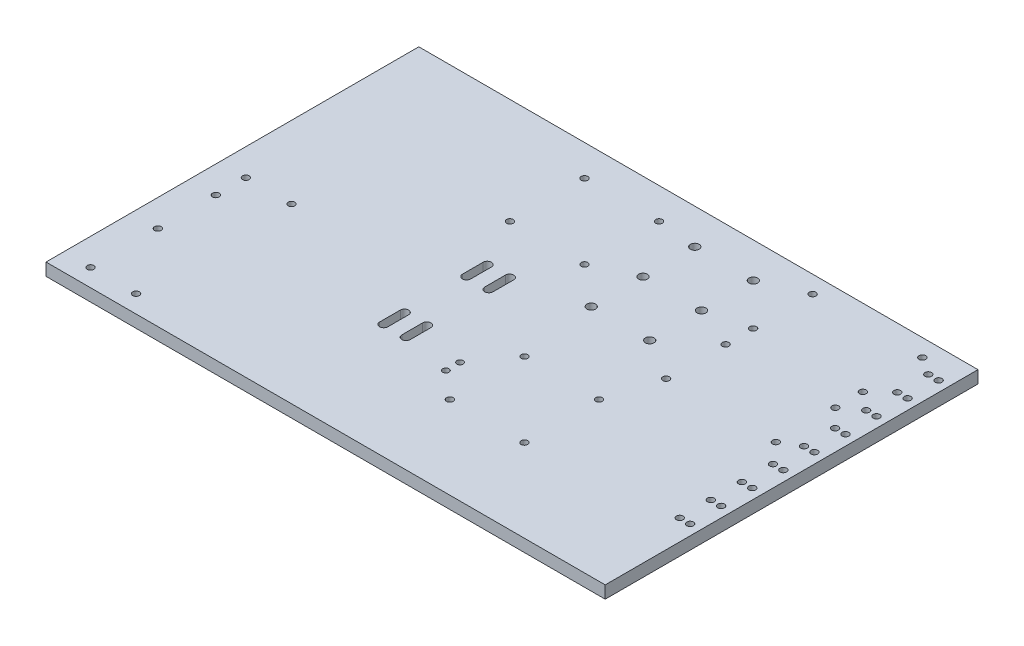
from build123d import *

# Parameters (mm, degrees)
SKETCH1_W           = 270
SKETCH1_H           = 180
BOSS_EXTRUDE1_DEPTH = 6
SKETCH2_R           = 1.6
CUT_EXTRUDE1_DEPTH  = 7
SKETCH3_R           = 1.6
CUT_EXTRUDE2_DEPTH  = 10
SKETCH4_R           = 1.6
SKETCH4_R_2         = 1.5
CUT_EXTRUDE3_DEPTH  = 7
SKETCH5_R           = 1.6
CUT_EXTRUDE4_DEPTH  = 10
SKETCH6_R           = 2.1
CUT_EXTRUDE5_DEPTH  = 10


with BuildPart() as part:
    # Sketch1 → Boss-Extrude1 (new body)
    with BuildSketch(Plane(origin=(0, 0, 0), x_dir=(1, 0, 0), z_dir=(0, 1, 0))):
        Rectangle(SKETCH1_W, SKETCH1_H)
    extrude(amount=BOSS_EXTRUDE1_DEPTH)

    # Sketch2 → Cut-Extrude1 (cut, through all)
    with BuildSketch(Plane.XZ):
        with Locations((-122, 81.5)):
            Circle(SKETCH2_R)
        with Locations((-100.000000181, 81.5)):
            Circle(SKETCH2_R)
        with Locations((-122, 6.500000003)):
            Circle(SKETCH2_R)
        with Locations((-100.000000181, 6.500000003)):
            Circle(SKETCH2_R)
        with Locations((-122, 21.000003407)):
            Circle(SKETCH2_R)
        with Locations((-122, 49.000003407)):
            Circle(SKETCH2_R)
    extrude(amount=-CUT_EXTRUDE1_DEPTH, mode=Mode.SUBTRACT)

    # Sketch3 → Cut-Extrude2 (cut)
    with BuildSketch(Plane.XZ):
        with Locations((-40, -39)):
            Circle(SKETCH3_R)
        with Locations((-40, -75)):
            Circle(SKETCH3_R)
        with Locations((-4, -75)):
            Circle(SKETCH3_R)
        with Locations((-4, -39)):
            Circle(SKETCH3_R)
        with BuildLine():
            Line((-29.38, -15.458502607), (-29.38, -5.458502607))
            ThreePointArc((-29.38, -5.458502607), (-27.38, -3.458502607), (-25.38, -5.458502607))
            Line((-25.38, -5.458502607), (-25.38, -15.458502607))
            ThreePointArc((-25.38, -15.458502607), (-27.38, -17.458502607), (-29.38, -15.458502607))
        make_face()
        with BuildLine():
            Line((-14.63, -15.458502607), (-14.63, -5.458502607))
            ThreePointArc((-14.63, -5.458502607), (-16.63, -3.458502607), (-18.63, -5.458502607))
            Line((-18.63, -5.458502607), (-18.63, -15.458502607))
            ThreePointArc((-18.63, -15.458502607), (-16.63, -17.458502607), (-14.63, -15.458502607))
        make_face()
        with BuildLine():
            Line((-29.38, 24.541497393), (-29.38, 34.541497393))
            ThreePointArc((-29.38, 34.541497393), (-27.38, 36.541497393), (-25.38, 34.541497393))
            Line((-25.38, 34.541497393), (-25.38, 24.541497393))
            ThreePointArc((-25.38, 24.541497393), (-27.38, 22.541497393), (-29.38, 24.541497393))
        make_face()
        with BuildLine():
            Line((-14.63, 24.541497393), (-14.63, 34.541497393))
            ThreePointArc((-14.63, 34.541497393), (-16.63, 36.541497393), (-18.63, 34.541497393))
            Line((-18.63, 34.541497393), (-18.63, 24.541497393))
            ThreePointArc((-18.63, 24.541497393), (-16.63, 22.541497393), (-14.63, 24.541497393))
        make_face()
    extrude(amount=-CUT_EXTRUDE2_DEPTH, mode=Mode.SUBTRACT)

    # Sketch4 → Cut-Extrude3 (cut, through all)
    with BuildSketch(Plane(origin=(0, 6, 0), x_dir=(1, 0, 0), z_dir=(0, 1, 0))):
        with Locations((19.999964, -14)):
            Circle(SKETCH4_R)
        with Locations((55.999928, -14.000072)):
            Circle(SKETCH4_R)
        with Locations((20, -50)):
            Circle(SKETCH4_R)
        with Locations((55.999928, -50)):
            Circle(SKETCH4_R)
        with Locations((6.904969305, -32.000108)):
            Circle(SKETCH4_R_2)
        with Locations((6.904969305, -38.817254)):
            Circle(SKETCH4_R_2)
    extrude(amount=-CUT_EXTRUDE3_DEPTH, mode=Mode.SUBTRACT)

    # Sketch5 → Cut-Extrude4 (cut)
    with BuildSketch(Plane(origin=(0, 6, 0), x_dir=(1, 0, 0), z_dir=(0, 1, 0))):
        with Locations((116.5, 10.91154574)):
            Circle(SKETCH5_R)
        with Locations((63.5, 10.91154574)):
            Circle(SKETCH5_R)
        with Locations((116.5, 39.629776512)):
            Circle(SKETCH5_R)
        with Locations((63.5, 39.629776512)):
            Circle(SKETCH5_R)
        with Locations((116.5, 52.91154574)):
            Circle(SKETCH5_R)
        with Locations((63.5, 52.91154574)):
            Circle(SKETCH5_R)
        with Locations((116.5, 81.629776512)):
            Circle(SKETCH5_R)
        with Locations((63.5, 81.629776512)):
            Circle(SKETCH5_R)
        with Locations((125, 76.00062614)):
            Circle(SKETCH5_R)
        with Locations((130, 76.00062614)):
            Circle(SKETCH5_R)
        with Locations((125, 61.00062614)):
            Circle(SKETCH5_R)
        with Locations((130, 61.00062614)):
            Circle(SKETCH5_R)
        with Locations((125, 46.00062614)):
            Circle(SKETCH5_R)
        with Locations((130, 46.00062614)):
            Circle(SKETCH5_R)
        with Locations((125, 31.00062614)):
            Circle(SKETCH5_R)
        with Locations((130, 31.00062614)):
            Circle(SKETCH5_R)
        with Locations((125, 16.00062614)):
            Circle(SKETCH5_R)
        with Locations((130, 16.00062614)):
            Circle(SKETCH5_R)
        with Locations((125, 1.00062614)):
            Circle(SKETCH5_R)
        with Locations((130, 1.00062614)):
            Circle(SKETCH5_R)
        with Locations((125, -13.99937386)):
            Circle(SKETCH5_R)
        with Locations((130, -13.99937386)):
            Circle(SKETCH5_R)
        with Locations((125, -28.99937386)):
            Circle(SKETCH5_R)
        with Locations((130, -28.99937386)):
            Circle(SKETCH5_R)
        with Locations((125, -43.99937386)):
            Circle(SKETCH5_R)
        with Locations((130, -43.99937386)):
            Circle(SKETCH5_R)
    extrude(amount=-CUT_EXTRUDE4_DEPTH, mode=Mode.SUBTRACT)

    # Sketch6 → Cut-Extrude5 (cut)
    with BuildSketch(Plane(origin=(0, 6, 0), x_dir=(1, 0, 0), z_dir=(0, 1, 0))):
        with Locations((15.26, 73)):
            Circle(SKETCH6_R)
        with Locations((43.5, 73)):
            Circle(SKETCH6_R)
        with Locations((15.26, 48)):
            Circle(SKETCH6_R)
        with Locations((43.5, 48)):
            Circle(SKETCH6_R)
        with Locations((15.26, 23)):
            Circle(SKETCH6_R)
        with Locations((43.5, 23)):
            Circle(SKETCH6_R)
    extrude(amount=-CUT_EXTRUDE5_DEPTH, mode=Mode.SUBTRACT)


solid = part.part
